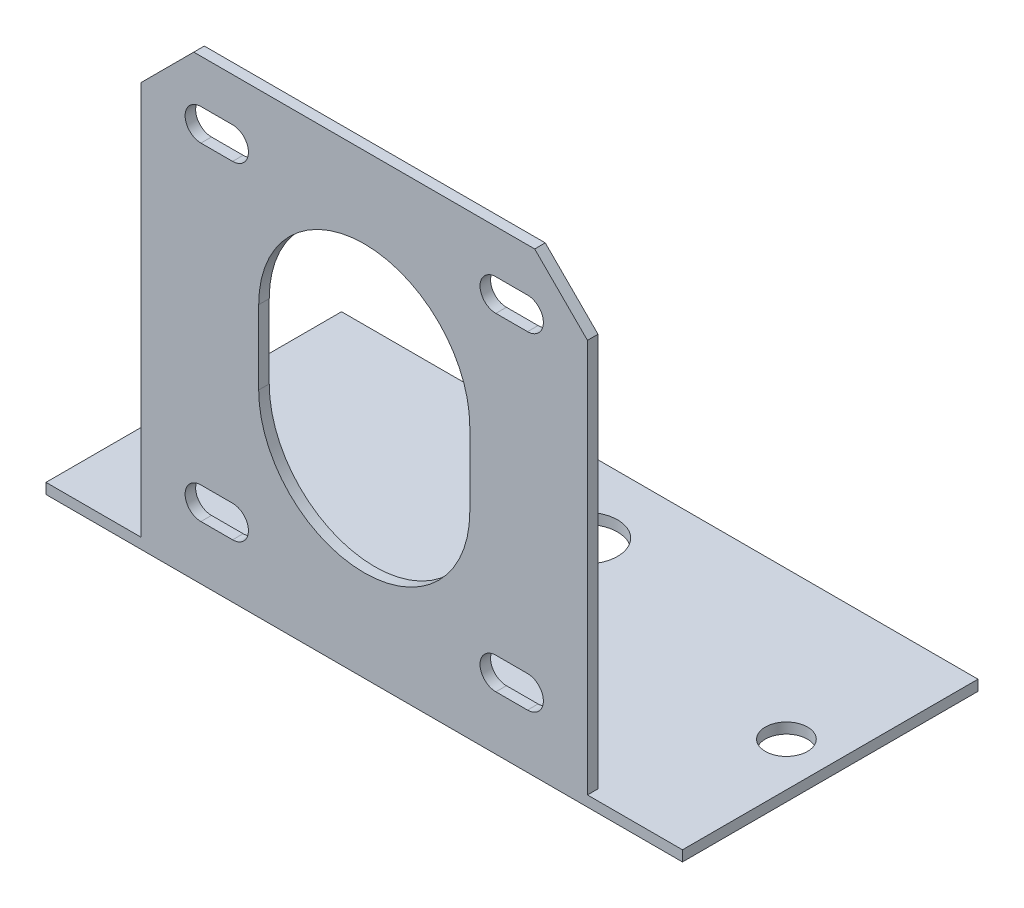
from build123d import *

# Parameters (mm, degrees)
SKETCH1_W                = 42.3
SKETCH1_H                = 42.3
BOSS_EXTRUDE1_DEPTH      = 1
SKETCH2_W                = 42.3
SKETCH2_H                = 1
BOSS_EXTRUDE2_DEPTH      = 10
CUT_EXTRUDE2_DEPTH       = 1
CUT_EXTRUDE4_DEPTH       = 10
MIRROR2_COPY_1_DEPTH     = 1
CHAMFER1_SIZE            = 5
SKETCH8_W                = 42.3
SKETCH8_H                = 1
BOSS_EXTRUDE3_DEPTH      = 27
BOSS_EXTRUDE3_DEPTH_BACK = 1
SKETCH5_R                = 3
CUT_EXTRUDE3_DEPTH       = 22
CUT_EXTRUDE5_REACH       = 44.3
SKETCH9_W                = 10
SKETCH9_H                = 1
BOSS_EXTRUDE4_DEPTH      = 9
SKETCH11_R               = 2
CUT_EXTRUDE6_DEPTH       = 10
SKETCH15_R               = 3
CUT_EXTRUDE8_DEPTH       = 10


with BuildPart() as part:
    # Sketch1 → Boss-Extrude1 (new body)
    with BuildSketch(Plane.XY):
        Rectangle(SKETCH1_W, SKETCH1_H)
    extrude(amount=BOSS_EXTRUDE1_DEPTH)

    # Sketch2 → Boss-Extrude2 (add)
    with BuildSketch(Plane.XY.offset(1)):
        with Locations((0, -20.65)):
            Rectangle(SKETCH2_W, SKETCH2_H)
    extrude(amount=BOSS_EXTRUDE2_DEPTH)

    # Sketch3 → Cut-Extrude2 (cut)
    with BuildSketch(Plane.XY.offset(1)):
        with BuildLine():
            Line((-15.470931569, -14.025299874), (-12.470931569, -14.025299874))
            ThreePointArc((-12.470931569, -14.025299874), (-10.970931569, -15.525299874), (-12.470931569, -17.025299874))
            Line((-12.470931569, -17.025299874), (-15.470931569, -17.025299874))
            ThreePointArc((-15.470931569, -17.025299874), (-16.970931569, -15.525299874), (-15.470931569, -14.025299874))
        make_face()
    cut_extrude2 = extrude(amount=-CUT_EXTRUDE2_DEPTH, mode=Mode.SUBTRACT)

    # Mirror1: Cut-Extrude2 across plane
    add(cut_extrude2.mirror(Plane(origin=(0, 0, 0), x_dir=(0, 0, 1), z_dir=(1, 0, 0))), mode=Mode.SUBTRACT)

    # Sketch6 → Cut-Extrude4 (cut)
    with BuildSketch(Plane.XY.offset(1)):
        with BuildLine():
            Line((10, 3.5), (10, -3.5))
            ThreePointArc((10, -3.5), (0, -13.5), (-10, -3.5))
            Line((-10, -3.5), (-10, 3.5))
            ThreePointArc((-10, 3.5), (0, 13.5), (10, 3.5))
        make_face()
    extrude(amount=-CUT_EXTRUDE4_DEPTH, mode=Mode.SUBTRACT)

    # Mirror2: Cut-Extrude2 across plane
    add(cut_extrude2.mirror(Plane.ZX), mode=Mode.SUBTRACT)

    # Mirror2 copy 1 sketch → Mirror2 copy 1 (cut)
    with BuildSketch(Plane(origin=(0, 0, 1), x_dir=(-1, 0, 0), z_dir=(0, 0, 1))):
        with BuildLine():
            Line((-15.470931569, -14.025299874), (-12.470931569, -14.025299874))
            ThreePointArc((-12.470931569, -14.025299874), (-10.970931569, -15.525299874), (-12.470931569, -17.025299874))
            Line((-12.470931569, -17.025299874), (-15.470931569, -17.025299874))
            ThreePointArc((-15.470931569, -17.025299874), (-16.970931569, -15.525299874), (-15.470931569, -14.025299874))
        make_face()
    extrude(amount=-MIRROR2_COPY_1_DEPTH, mode=Mode.SUBTRACT)

    # Chamfer1
    chamfer1_edges = [part.edges().sort_by_distance(p)[0] for p in [
        (-21.15, 21.15, 0.5),
        (21.15, 21.15, 0.5),
    ]]
    chamfer(chamfer1_edges, length=CHAMFER1_SIZE)

    # Sketch8 → Boss-Extrude3 (add, two sides)
    with BuildSketch(Plane(origin=(0, 0, 0), x_dir=(-1, 0, 0), z_dir=(0, 0, -1))) as boss_extrude3_sk:
        with Locations((0, -21.65)):
            Rectangle(SKETCH8_W, SKETCH8_H)
    extrude(amount=BOSS_EXTRUDE3_DEPTH)
    extrude(boss_extrude3_sk.sketch, amount=-BOSS_EXTRUDE3_DEPTH_BACK)

    # Sketch5 → Cut-Extrude3 (cut)
    with BuildSketch(Plane(origin=(0, -20.15, 0), x_dir=(1, 0, 0), z_dir=(0, 1, 0))):
        with Locations((0, -6)):
            Circle(SKETCH5_R)
    extrude(amount=-CUT_EXTRUDE3_DEPTH, mode=Mode.SUBTRACT)

    # Sketch9 → Cut-Extrude5 (cut, up to next)
    with BuildSketch(Plane(origin=(21.15, 0, 0), x_dir=(0, 0, -1), z_dir=(1, 0, 0)), mode=Mode.PRIVATE) as cut_extrude5_sk1:
        with Locations((-6, -20.65)):
            Rectangle(SKETCH9_W, SKETCH9_H)
    cut_extrude5_tool1 = extrude(cut_extrude5_sk1.sketch, amount=-CUT_EXTRUDE5_REACH, mode=Mode.PRIVATE) & part.part
    add(cut_extrude5_tool1.solids().sort_by_distance((21.15, -20.65, 6))[0], mode=Mode.SUBTRACT)

    # Sketch10 → Boss-Extrude4 (add)
    with BuildSketch(Plane(origin=(21.15, 0, 0), x_dir=(0, 0, -1), z_dir=(1, 0, 0))):
        Polygon((0, -21.15), (-1, -21.15), (-1, -22.15), (0, -22.15), (27, -22.15), (27, -21.15), align=None)
    boss_extrude4 = extrude(amount=BOSS_EXTRUDE4_DEPTH)

    # Mirror3: Boss-Extrude4 across plane
    add(boss_extrude4.mirror(Plane(origin=(0, 0, 0), x_dir=(0, 0, 1), z_dir=(1, 0, 0))))

    # Sketch11 → Cut-Extrude6 (cut)
    with BuildSketch(Plane(origin=(0, -21.15, 0), x_dir=(1, 0, 0), z_dir=(0, 1, 0))):
        with Locations((26, 13)):
            Circle(SKETCH11_R)
        with Locations((-26, 13)):
            Circle(SKETCH11_R)
    extrude(amount=-CUT_EXTRUDE6_DEPTH, mode=Mode.SUBTRACT)

    # Sketch15 → Cut-Extrude8 (cut)
    with BuildSketch(Plane(origin=(0, -21.15, 0), x_dir=(1, 0, 0), z_dir=(0, 1, 0))):
        with Locations((0, 20)):
            Circle(SKETCH15_R)
    extrude(amount=-CUT_EXTRUDE8_DEPTH, mode=Mode.SUBTRACT)


solid = part.part
